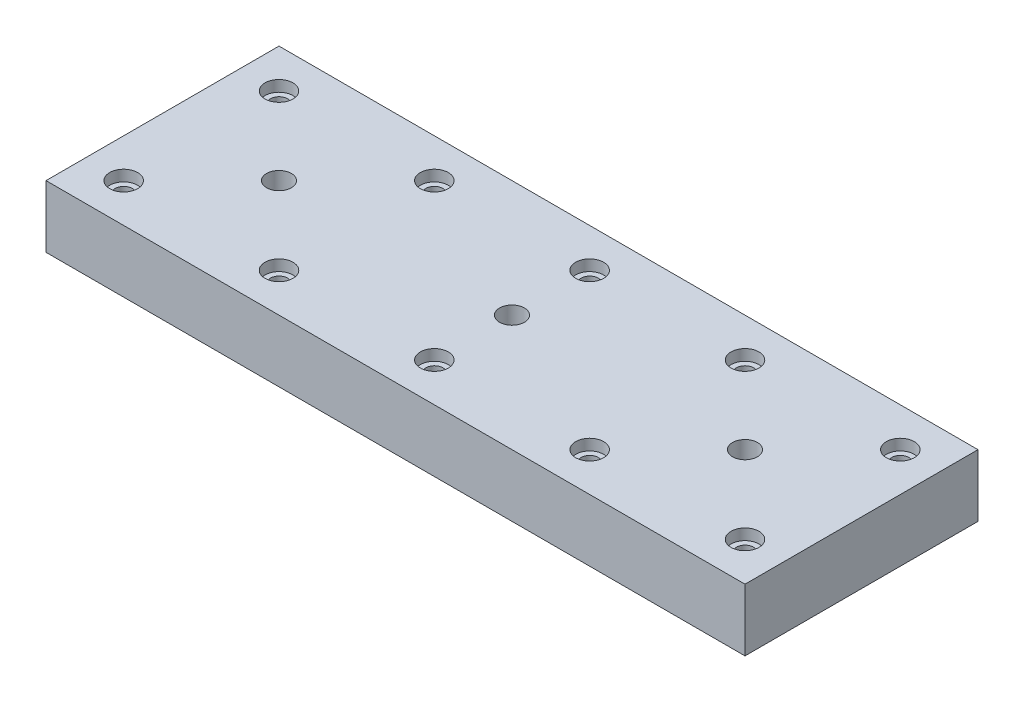
from build123d import *

# Parameters (mm, degrees)
ESBO_O1_W                                            = 450
ESBO_O1_H                                            = 150
RESSALTO_EXTRUS_O1_DEPTH                             = 40
REBAIXO_PARA_PARAFUSO_ALLEN_SEXTAVADO_DE_D           = 11
REBAIXO_PARA_PARAFUSO_ALLEN_SEXTAVADO_DE_DEPTH       = 40
REBAIXO_PARA_PARAFUSO_ALLEN_SEXTAVADO_DE_CBORE_D     = 18
REBAIXO_PARA_PARAFUSO_ALLEN_SEXTAVADO_DE_CBORE_DEPTH = 7.1
FURO_ROSCADO_DE_M18X2_0_D                            = 16
FURO_ROSCADO_DE_M18X2_0_DEPTH                        = 40


with BuildPart() as part:
    # Esboço1 → Ressalto-extrusão1 (new body)
    with BuildSketch(Plane(origin=(0, 0, 0), x_dir=(1, 0, 0), z_dir=(0, 1, 0))):
        Rectangle(ESBO_O1_W, ESBO_O1_H)
    extrude(amount=RESSALTO_EXTRUS_O1_DEPTH)

    # Rebaixo para parafuso Allen sextavado de M101
    with Locations(Plane(origin=(0, 40, 0), x_dir=(1, 0, 0), z_dir=(0, 1, 0))):
        with Locations((-200, 50), (-100, 50), (0, 50), (100, 50), (200, 50), (-100, -50), (0, -50), (100, -50), (200, -50), (-200, -50)):
            CounterBoreHole(REBAIXO_PARA_PARAFUSO_ALLEN_SEXTAVADO_DE_D / 2, REBAIXO_PARA_PARAFUSO_ALLEN_SEXTAVADO_DE_CBORE_D / 2, REBAIXO_PARA_PARAFUSO_ALLEN_SEXTAVADO_DE_CBORE_DEPTH, depth=REBAIXO_PARA_PARAFUSO_ALLEN_SEXTAVADO_DE_DEPTH)

    # Furo roscado de M18x2.0
    with Locations(Plane(origin=(0, 40, 0), x_dir=(1, 0, 0), z_dir=(0, 1, 0))):
        with Locations((0, 0), (150, 0), (-150, 0)):
            Hole(FURO_ROSCADO_DE_M18X2_0_D / 2, depth=FURO_ROSCADO_DE_M18X2_0_DEPTH)


solid = part.part
